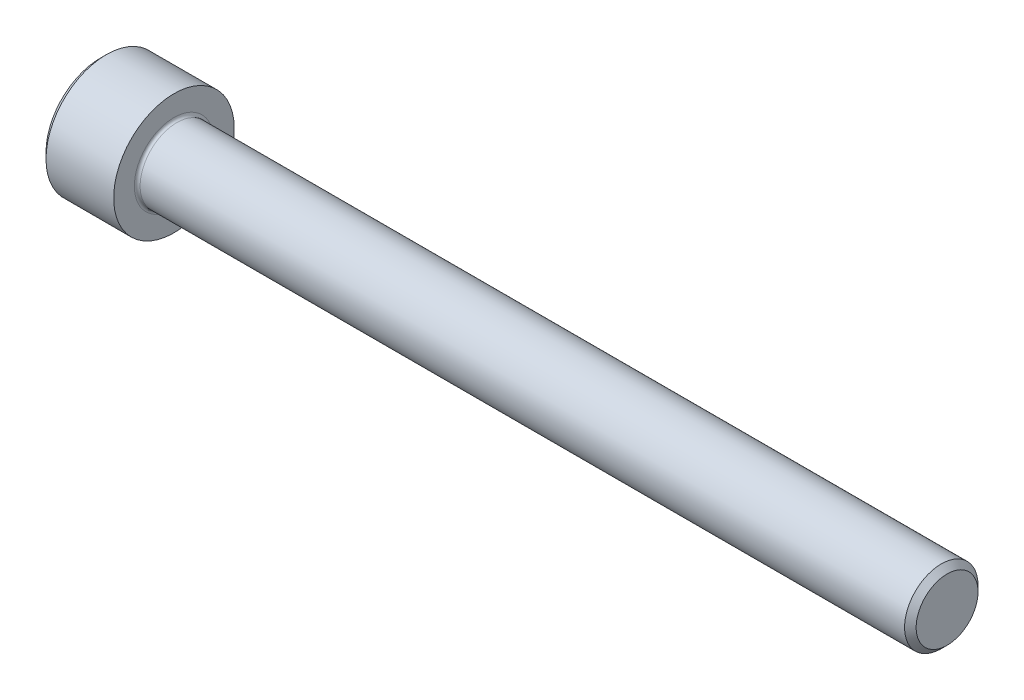
from build123d import *

# Parameters (mm, degrees)
HEX_START         = -3.217333
HEX_2_DEPTH       = 3.217333
CHAMFER1_SIZE     = 0.381
FILLET1_R         = 0.1905
SKETCH3_R         = 2.291358881
HEX_CHAMFER_DEPTH = 2.54
HEX_CHAMFER_DRAFT = 45


with BuildPart() as part:
    # Sketch1 → Body (revolve)
    with BuildSketch(Plane(origin=(0, 0, 0), x_dir=(1, 0, 0), z_dir=(0, 1, 0))):
        Polygon((0, 0), (0, 3.9624), (4.826, 3.9624), (4.826, 2.413), (55.626, 2.413), (55.626, 0), align=None)
    revolve(axis=Axis((55.626, 0, 0), (-1, 0, 0)))

    # Sketch2 → Hex 2 (cut)
    with BuildSketch(Plane.ZY.offset(HEX_START)):
        Polygon((-2.291358881, 0), (-1.14567944, -1.984375), (1.14567944, -1.984375), (2.291358881, 0), (1.14567944, 1.984375), (-1.14567944, 1.984375), align=None)
    extrude(amount=HEX_2_DEPTH, mode=Mode.SUBTRACT)

    # Chamfer1
    chamfer1_edges = [part.edges().sort_by_distance(p)[0] for p in [
        (0, 0, 3.9624),
        (55.626, 0, 2.413),
    ]]
    chamfer(chamfer1_edges, length=CHAMFER1_SIZE)

    # Fillet1
    fillet1_edges = [part.edges().sort_by_distance(p)[0] for p in [
        (4.826, 0, 2.413),
    ]]
    fillet(fillet1_edges, radius=FILLET1_R)


with BuildPart() as hex_chamfer_tool:
    # Sketch3 → Hex Chamfer (with draft: the straight prism first)
    with BuildSketch(Plane(origin=(0, 0, 0), x_dir=(0, 0, -1), z_dir=(1, 0, 0))):
        Circle(SKETCH3_R)
    extrude(amount=HEX_CHAMFER_DEPTH)
    # Hex Chamfer: the draft: its side faces are tilted about the plane it starts from
    hex_chamfer_sides = [hex_chamfer_tool.faces().sort_by_distance(p)[0] for p in [
        (1.27, 0, 2.291358881),
    ]]
    draft(hex_chamfer_sides, Plane(origin=(0, 0, 0), x_dir=(0, 0, -1), z_dir=(1, 0, 0)), HEX_CHAMFER_DRAFT)


with BuildPart() as part_1:
    add(part.part)

    # Hex Chamfer: cut by hex_chamfer_tool
    add(hex_chamfer_tool.part, mode=Mode.SUBTRACT)


solid = part_1.part
